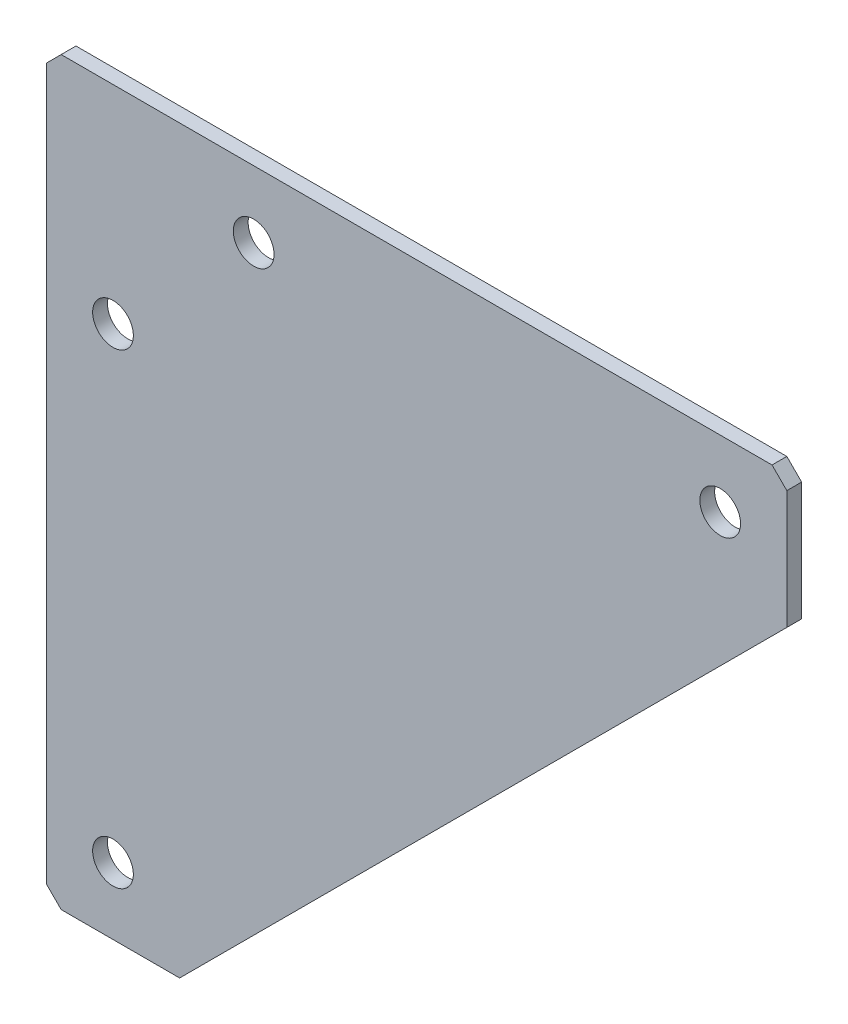
from build123d import *

# Parameters (mm, degrees)
SKETCH1_R           = 2.75
BOSS_EXTRUDE1_DEPTH = 2


with BuildPart() as part:
    # Sketch1 → Boss-Extrude1 (new body)
    with BuildSketch(Plane.XY):
        Polygon((0, 98), (0, 2), (2, 0), (18, 0), (100, 82), (100, 98), (98, 100), (2, 100), align=None)
        with Locations((91, 91)):
            Circle(SKETCH1_R, mode=Mode.SUBTRACT)
        with Locations((28, 91)):
            Circle(SKETCH1_R, mode=Mode.SUBTRACT)
        with Locations((9, 9)):
            Circle(SKETCH1_R, mode=Mode.SUBTRACT)
        with Locations((9, 72)):
            Circle(SKETCH1_R, mode=Mode.SUBTRACT)
    extrude(amount=-BOSS_EXTRUDE1_DEPTH)


solid = part.part
